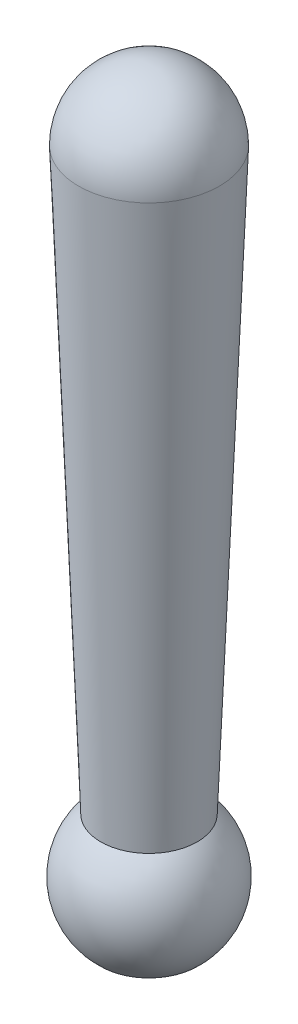
from build123d import *

# Parameters (mm, degrees)
SKETCH1_R         = 1.46
SKETCH2_R         = 1
DOME1_FACE_RADIUS = 1.46
DOME1_HEIGHT      = 1.46


with BuildPart() as part:
    # Sketch1 → Loft1 section 0
    with BuildSketch(Plane(origin=(0, 0, 0), x_dir=(1, 0, 0), z_dir=(0, 1, 0))):
        Circle(SKETCH1_R)
    # Sketch2 → Loft1 section 1
    with BuildSketch(Plane(origin=(0, -12, 0), x_dir=(1, 0, 0), z_dir=(0, 1, 0))):
        Circle(SKETCH2_R)
    loft()

    # Dome1: a dome of height H over a round flat face of radius A is a cap of a sphere of radius (A * A + H * H) / (2 * H)
    dome1_r = (DOME1_FACE_RADIUS * DOME1_FACE_RADIUS + DOME1_HEIGHT * DOME1_HEIGHT) / (2 * DOME1_HEIGHT)
    dome1_base = Plane((0, 0, 0), z_dir=(0, 1, 0))
    with Locations(dome1_base.offset(DOME1_HEIGHT - dome1_r)):
        dome1_ball = Sphere(dome1_r, mode=Mode.PRIVATE)
    add(split(dome1_ball, bisect_by=dome1_base, keep=Keep.TOP, mode=Mode.PRIVATE))

    # Sketch3 → Revolve3 (revolve)
    with BuildSketch(Plane.XY, mode=Mode.PRIVATE) as revolve3_sk:
        with BuildLine():
            Line((0, -12), (0, -14.236067977))
            Line((0, -14.236067977), (1, -14.236067977))
            ThreePointArc((1, -14.236067977), (1.5, -13.118033989), (1, -12))
            Line((1, -12), (0, -12))
        make_face()
    revolve(revolve3_sk.sketch.rotate(Axis((0, -12, 0), (0, -1, 0)), 270), axis=Axis((0, -12, 0), (0, -1, 0)))


solid = part.part
